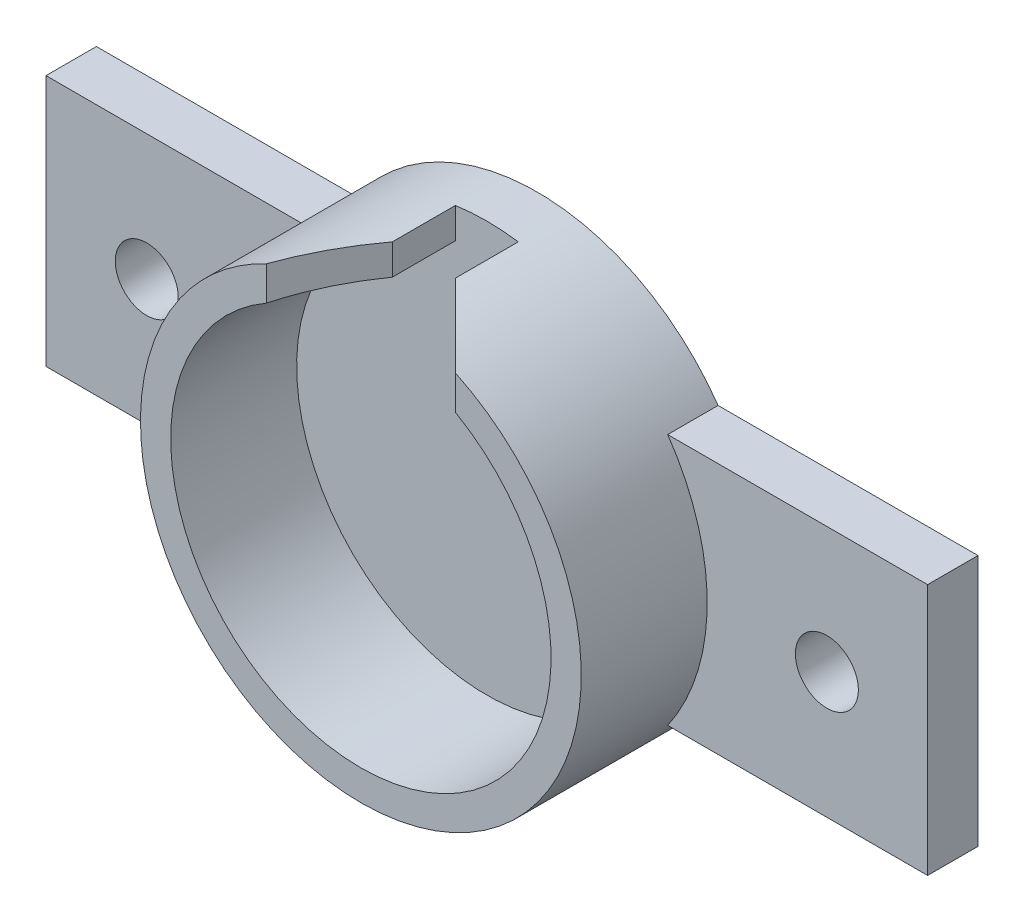
from build123d import *

# Parameters (mm, degrees)
SKETCH1_R           = 17.5
SKETCH1_R_2         = 15.1
BOSS_EXTRUDE1_DEPTH = 10
BOSS_EXTRUDE2_DEPTH = 4
SKETCH3_R           = 2.5
CUT_EXTRUDE1_DEPTH  = 4
SKETCH4_W           = 5
SKETCH4_H           = 8
CUT_EXTRUDE2_DEPTH  = 10
CHAMFER1_SIZE       = 5


with BuildPart() as part:
    # Sketch1 → Boss-Extrude1 (new body)
    with BuildSketch(Plane.XY):
        Circle(SKETCH1_R)
        Circle(SKETCH1_R_2, mode=Mode.SUBTRACT)
    extrude(amount=BOSS_EXTRUDE1_DEPTH)

    # Sketch2 → Boss-Extrude2 (add)
    with BuildSketch(Plane(origin=(0, 0, 0), x_dir=(-1, 0, 0), z_dir=(0, 0, -1))):
        with BuildLine():
            Line((14.361406616, 10), (35, 10))
            Line((35, 10), (35, -10))
            Line((35, -10), (14.361406616, -10))
            ThreePointArc((14.361406616, -10), (0, -17.5), (-14.361406616, -10))
            Line((-14.361406616, -10), (-35, -10))
            Line((-35, -10), (-35, 10))
            Line((-35, 10), (-14.361406616, 10))
            ThreePointArc((-14.361406616, 10), (0, 17.5), (14.361406616, 10))
        make_face()
    extrude(amount=BOSS_EXTRUDE2_DEPTH)

    # Sketch3 → Cut-Extrude1 (cut)
    with BuildSketch(Plane.XY):
        with Locations((-27, 0)):
            Circle(SKETCH3_R)
        with Locations((27, 0)):
            Circle(SKETCH3_R)
    extrude(amount=-CUT_EXTRUDE1_DEPTH, mode=Mode.SUBTRACT)

    # Sketch4 → Cut-Extrude2 (cut)
    with BuildSketch(Plane.XY.offset(10)):
        with Locations((0, 15.1)):
            Rectangle(SKETCH4_W, SKETCH4_H)
    extrude(amount=-CUT_EXTRUDE2_DEPTH, mode=Mode.SUBTRACT)

    # Chamfer1
    chamfer1_edges = [part.edges().sort_by_distance(p)[0] for p in [
        (2.5, 16.106058225, 10),
        (-2.5, 16.106058225, 10),
    ]]
    chamfer(chamfer1_edges, length=CHAMFER1_SIZE)


solid = part.part
